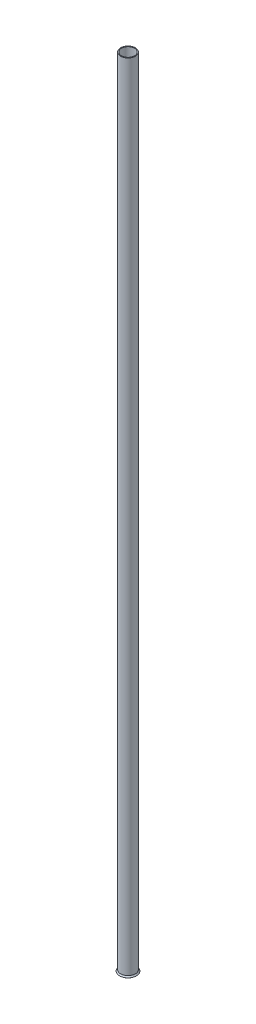
from build123d import *

# Parameters (mm, degrees)
SKETCH1_R           = 28.575
SKETCH1_R_2         = 25.4
BOSS_EXTRUDE1_DEPTH = 3085.846


with BuildPart() as part:
    # Sketch1 → Boss-Extrude1 (new body)
    with BuildSketch(Plane(origin=(0, 0, 0), x_dir=(1, 0, 0), z_dir=(0, 1, 0))):
        Circle(SKETCH1_R)
        Circle(SKETCH1_R_2, mode=Mode.SUBTRACT)
    extrude(amount=BOSS_EXTRUDE1_DEPTH)

    # Sketch3 → Revolve1 (revolve)
    with BuildSketch(Plane.XY):
        Polygon((28.575, 0), (32.656701322, -4.864382214), (30.793534839, -6.427764522), (25.4, 0), align=None)
    revolve(axis=Axis((0, -154.2923, 0), (0, 1, 0)))


solid = part.part
